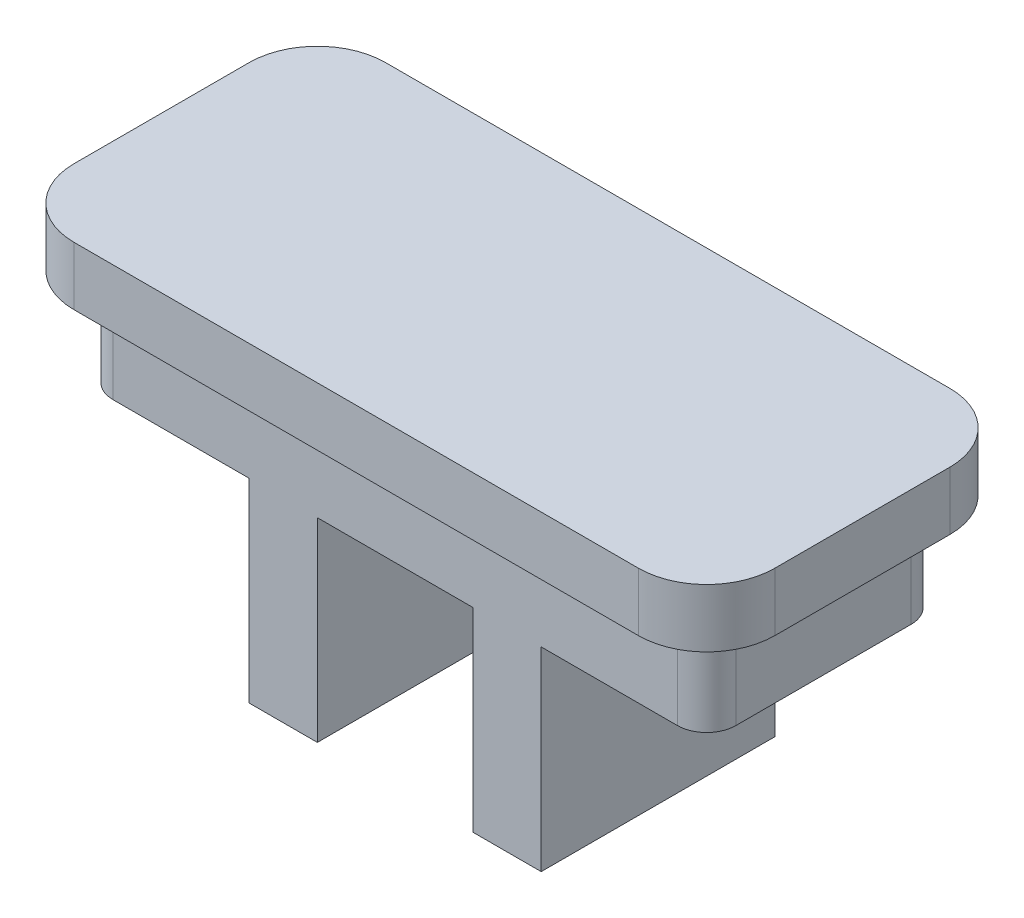
from build123d import *

# Parameters (mm, degrees)
BOSS_EXTRUDE1_DEPTH = 15
BOSS_EXTRUDE2_DEPTH = 3
SKETCH3_W           = 8
SKETCH3_H           = 12
CUT_EXTRUDE1_DEPTH  = 10
CUT_EXTRUDE3_DEPTH  = 10


with BuildPart() as part:
    # Sketch1 → Boss-Extrude1 (new body)
    with BuildSketch(Plane(origin=(0, 0, 0), x_dir=(1, 0, 0), z_dir=(0, 1, 0))):
        with BuildLine():
            Line((1.5, 0), (30.5, 0))
            ThreePointArc((30.5, 0), (31.560660172, 0.439339828), (32, 1.5))
            Line((32, 1.5), (32, 10.5))
            ThreePointArc((32, 10.5), (31.560660172, 11.560660172), (30.5, 12))
            Line((30.5, 12), (1.5, 12))
            ThreePointArc((1.5, 12), (0.439339828, 11.560660172), (0, 10.5))
            Line((0, 10.5), (0, 1.5))
            ThreePointArc((0, 1.5), (0.439339828, 0.439339828), (1.5, 0))
        make_face()
    extrude(amount=BOSS_EXTRUDE1_DEPTH)

    # Sketch2 → Boss-Extrude2 (add)
    with BuildSketch(Plane(origin=(0, 15, 0), x_dir=(1, 0, 0), z_dir=(0, 1, 0))):
        with BuildLine():
            Line((1.5, -2), (30.5, -2))
            ThreePointArc((30.5, -2), (32.974873734, -0.974873734), (34, 1.5))
            Line((34, 1.5), (34, 10.5))
            ThreePointArc((34, 10.5), (32.974873734, 12.974873734), (30.5, 14))
            Line((30.5, 14), (1.5, 14))
            ThreePointArc((1.5, 14), (-0.974873734, 12.974873734), (-2, 10.5))
            Line((-2, 10.5), (-2, 1.5))
            ThreePointArc((-2, 1.5), (-0.974873734, -0.974873734), (1.5, -2))
        make_face()
        with BuildLine():
            ThreePointArc((32, 10.5), (31.560660172, 11.560660172), (30.5, 12))
            Line((30.5, 12), (1.5, 12))
            ThreePointArc((1.5, 12), (0.439339828, 11.560660172), (0, 10.5))
            Line((0, 10.5), (0, 1.5))
            ThreePointArc((0, 1.5), (0.439339828, 0.439339828), (1.5, 0))
            Line((1.5, 0), (30.5, 0))
            ThreePointArc((30.5, 0), (31.560660172, 0.439339828), (32, 1.5))
            Line((32, 1.5), (32, 10.5))
        make_face(mode=Mode.SUBTRACT)
        with BuildLine():
            Line((32, 1.5), (32, 10.5))
            ThreePointArc((32, 10.5), (31.560660172, 11.560660172), (30.5, 12))
            Line((30.5, 12), (1.5, 12))
            ThreePointArc((1.5, 12), (0.439339828, 11.560660172), (0, 10.5))
            Line((0, 10.5), (0, 1.5))
            ThreePointArc((0, 1.5), (0.439339828, 0.439339828), (1.5, 0))
            Line((1.5, 0), (30.5, 0))
            ThreePointArc((30.5, 0), (31.560660172, 0.439339828), (32, 1.5))
        make_face()
    extrude(amount=BOSS_EXTRUDE2_DEPTH)

    # Sketch3 → Cut-Extrude1 (cut)
    with BuildSketch(Plane.XZ):
        with Locations((16, -6)):
            Rectangle(SKETCH3_W, SKETCH3_H)
    extrude(amount=-CUT_EXTRUDE1_DEPTH, mode=Mode.SUBTRACT)

    # Sketch4 → Cut-Extrude3 (cut)
    with BuildSketch(Plane.XZ):
        with BuildLine():
            Line((8.5, 0), (1.5, 0))
            ThreePointArc((1.5, 0), (0.439339828, -0.439339828), (0, -1.5))
            Line((0, -1.5), (0, -10.5))
            ThreePointArc((0, -10.5), (0.439339828, -11.560660172), (1.5, -12))
            Line((1.5, -12), (8.5, -12))
            Line((8.5, -12), (8.5, 0))
        make_face()
        with BuildLine():
            Line((23.5, -12), (30.5, -12))
            ThreePointArc((30.5, -12), (31.560660172, -11.560660172), (32, -10.5))
            Line((32, -10.5), (32, -1.5))
            ThreePointArc((32, -1.5), (31.560660172, -0.439339828), (30.5, 0))
            Line((30.5, 0), (23.5, 0))
            Line((23.5, 0), (23.5, -12))
        make_face()
    extrude(amount=-CUT_EXTRUDE3_DEPTH, mode=Mode.SUBTRACT)


solid = part.part
